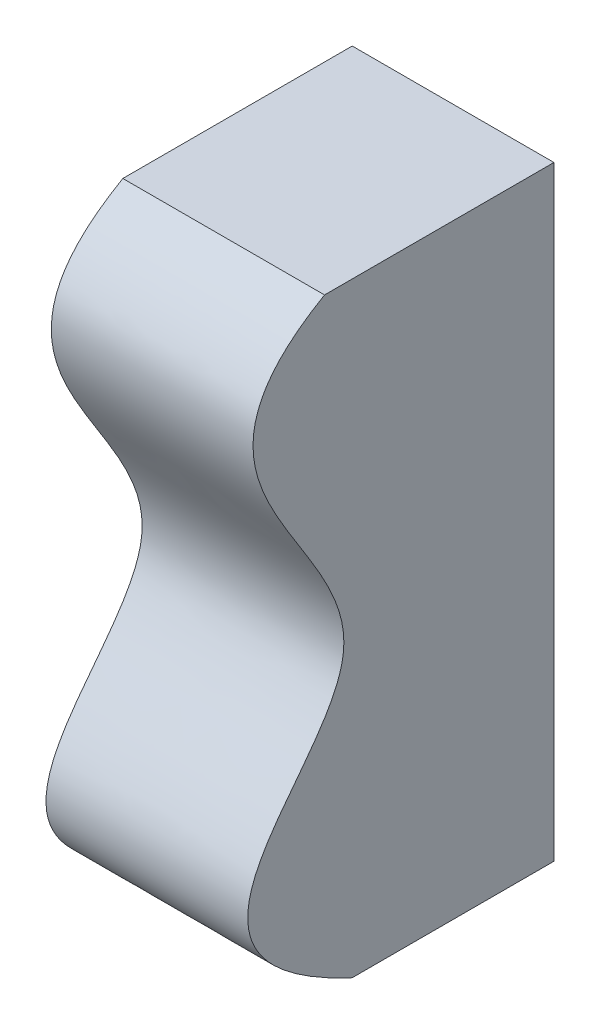
from build123d import *

# Parameters (mm, degrees)
BOSS_EXTRUDE1_DEPTH = 2.54


with BuildPart() as part:
    # Sketch1 → Boss-Extrude1 (new body)
    with BuildSketch(Plane.YZ):
        with BuildLine():
            Line((0, 0), (0, -2.54))
            Line((0, -2.54), (7.62, -2.54))
            Line((7.62, -2.54), (7.62, 0.348694482))
            add(Edge.make_bspline(
                [(0, 0), (1.308712736, 2.812029335), (3.549886227, -2.485290349), (6.334938826, 2.576406426), (7.62, 0.348694482)],
                knots=[0, 0, 0, 0, 0.480789823, 1, 1, 1, 1], degree=3))
        make_face()
    extrude(amount=BOSS_EXTRUDE1_DEPTH)


solid = part.part
